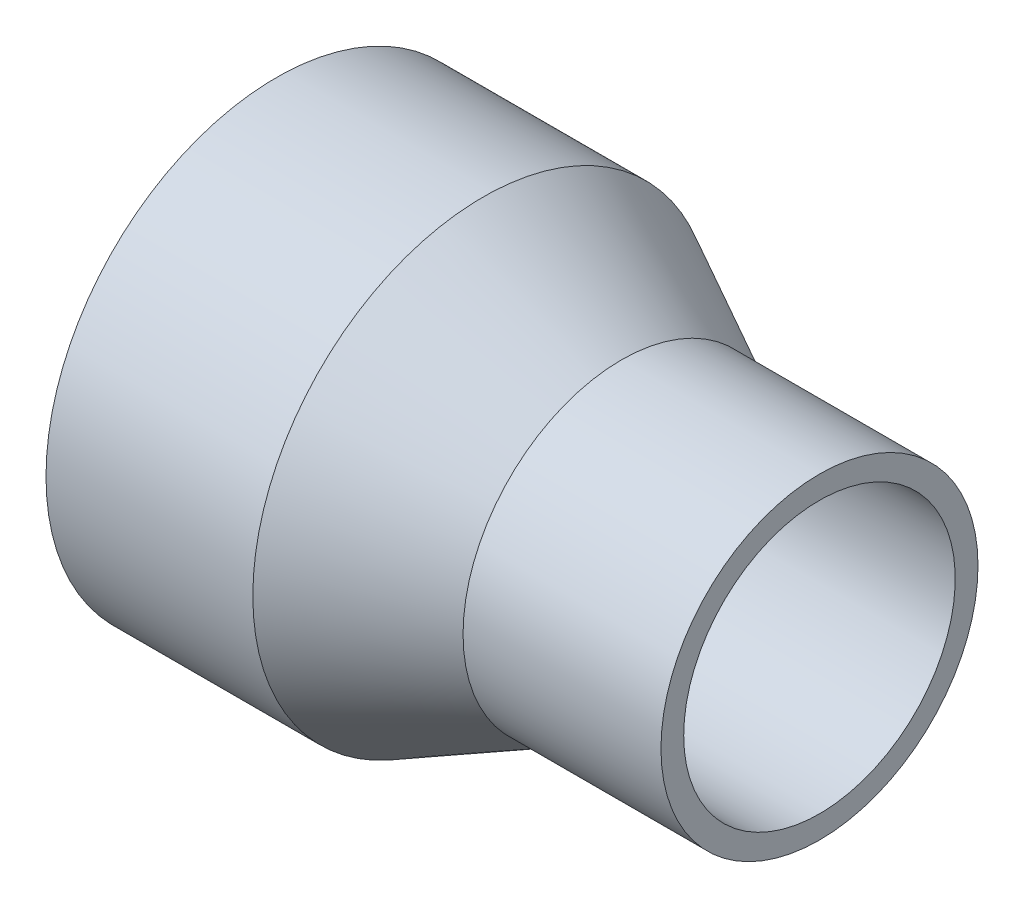
from build123d import *


with BuildPart() as part:
    # Sketch1 → Revolve1 (revolve)
    with BuildSketch(Plane.XY):
        Polygon((0, 43.1), (0, 38.1), (4.431577029, 38.1), (38.691391356, 38.1), (64.576381155, 25.4), (101.6, 25.4), (101.6, 29.656023939), (64.576381155, 29.656023939), (38.691391356, 43.1), (4.431577029, 43.1), align=None)
    revolve(axis=Axis((0, 0, 0), (1, 0, 0)))


solid = part.part
